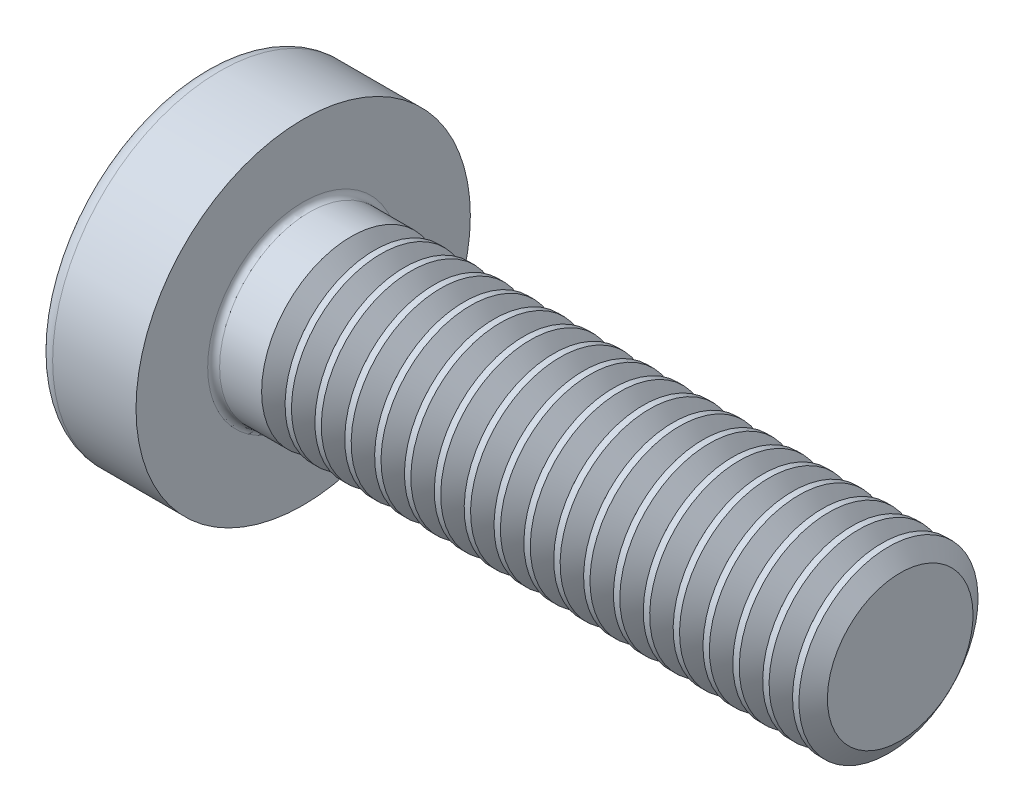
from build123d import *

# Parameters (mm, degrees)
FILLET1_R       = 0.1
SKETCH3_W       = 0.74
SKETCH3_H       = 2.8
SKETCH4_W       = 0.74
SKETCH4_H       = 1.054964432
RECPAT_COUNT    = 2
RECPAT_ANGLE    = 90
THDSCHPAT_COUNT = 19
THDSCHPAT_PITCH = 0.5


with BuildPart() as part:
    # BodySke → Base-Revolve (revolve)
    with BuildSketch(Plane.XY):
        with BuildLine():
            Line((2.4, 1.5), (2.4, 2.8))
            Line((2.4, 2.8), (1.003501533, 2.8))
            ThreePointArc((1.003501533, 2.8), (0.873295971, 2.76653015), (0.775371599, 2.674418605))
            ThreePointArc((0.775371599, 2.674418605), (0.197753546, 1.392274756), (0, 0))
            Line((0, 0), (12.4, 0))
            Line((12.4, 0), (12.4, 1.5))
            Line((12.4, 1.5), (2.4, 1.5))
        make_face()
    revolve(axis=Axis((-25.4, 0, 0), (1, 0, 0)))

    # Fillet1
    fillet1_edges = [part.edges().sort_by_distance(p)[0] for p in [
        (2.4, -1.5, 0),
    ]]
    fillet(fillet1_edges, radius=FILLET1_R)

    # Sketch3 → Recess section 0
    with BuildSketch(Plane(origin=(0, 0, 0), x_dir=(0, 0, -1), z_dir=(1, 0, 0))):
        Rectangle(SKETCH3_W, SKETCH3_H)
    # Sketch4 → Recess section 1
    with BuildSketch(Plane(origin=(1.75, 0, 0), x_dir=(0, 0, -1), z_dir=(1, 0, 0))):
        Rectangle(SKETCH4_W, SKETCH4_H)
    recess = loft(mode=Mode.SUBTRACT)

    # RecPat: Recess ×2 about axis
    recpat_axis = Axis((0, 0, 0), (1, 0, 0))
    for i in range(1, RECPAT_COUNT):
        add(recess.rotate(recpat_axis, i * RECPAT_ANGLE / (RECPAT_COUNT - 1)), mode=Mode.SUBTRACT)

    # RecCorSke → RecessCore (revolve, cut)
    with BuildSketch(Plane.XY):
        Polygon((0, 0), (0, 0.678371921), (1.75, 0.556), (1.930655351, 0), align=None)
    revolve(axis=Axis((-3.175, 0, 0), (1, 0, 0)), mode=Mode.SUBTRACT)

    # ThdSchSke → ThreadSchematic (revolve, cut)
    with BuildSketch(Plane.XY):
        Polygon((3.4, -1.2195), (3.203591786, -1.5), (3.203591786, -1.875), (3.596408214, -1.875), (3.596408214, -1.5), align=None)
    threadschematic = revolve(axis=Axis((-3.175, 0, 0), (1, 0, 0)), mode=Mode.SUBTRACT)

    # ThdSchPat: ThreadSchematic ×19
    with Locations(*[(i * THDSCHPAT_PITCH, 0, 0) for i in range(1, THDSCHPAT_COUNT)]):
        add(threadschematic, mode=Mode.SUBTRACT)


solid = part.part
